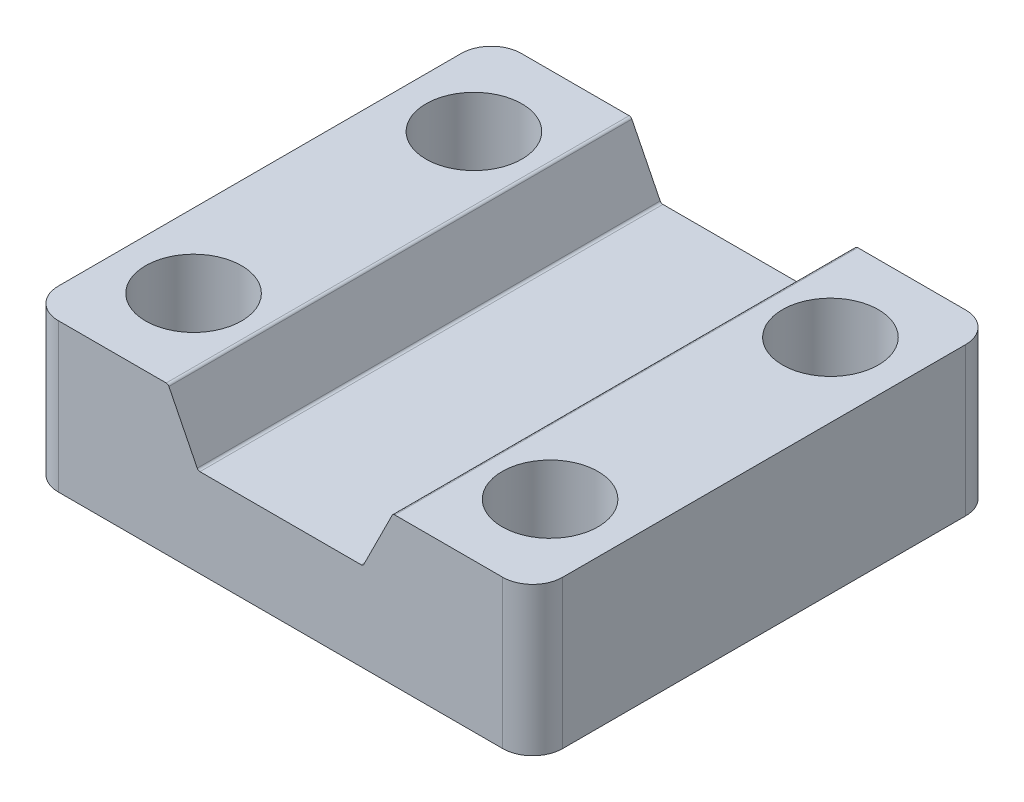
from build123d import *

# Parameters (mm, degrees)
ESQUISSE1_W             = 42.7228
ESQUISSE1_H             = 39.2176
BOSS_EXTRU_1_DEPTH      = 12.573
ESQUISSE2_W             = 13.97
ESQUISSE2_H             = 5.08
ENL_V_MAT_EXTRU_1_DEPTH = 40.2176
D_POUILLE1_ANGLE        = 26.565051177
PER_AGE1_D              = 8.128
PER_AGE1_DEPTH          = 12.573
CONG_1_R                = 0.254
CONG_2_R                = 2.54


with BuildPart() as part:
    # Esquisse1 → Boss.-Extru.1 (new body)
    with BuildSketch(Plane(origin=(0, 12.573, 0), x_dir=(1, 0, 0), z_dir=(0, 1, 0))):
        Rectangle(ESQUISSE1_W, ESQUISSE1_H)
    extrude(amount=-BOSS_EXTRU_1_DEPTH)

    # Esquisse2 → Enlèv. mat.-Extru.1 (cut, through all)
    with BuildSketch(Plane(origin=(0, 0, -19.6088), x_dir=(-1, 0, 0), z_dir=(0, 0, -1))):
        with Locations((0, 10.033)):
            Rectangle(ESQUISSE2_W, ESQUISSE2_H)
    extrude(amount=-ENL_V_MAT_EXTRU_1_DEPTH, mode=Mode.SUBTRACT)

    # Dépouille1
    d_pouille1_faces = [part.faces().sort_by_distance(p)[0] for p in [
        (-6.985, 10.033, 0),
        (6.985, 10.033, 0),
    ]]
    draft(d_pouille1_faces, Plane(origin=(6.985, 7.493, 19.6088), x_dir=(0, 0, 1), z_dir=(0, 1, 0)), D_POUILLE1_ANGLE)

    # Perçage1
    with Locations(Plane(origin=(0, 12.573, 0), x_dir=(1, 0, 0), z_dir=(0, 1, 0))):
        with Locations((15.1003, -11.8745), (-15.1003, 11.8745), (15.1003, 11.8745), (-15.1003, -11.8745)):
            Hole(PER_AGE1_D / 2, depth=PER_AGE1_DEPTH)

    # Congé1
    cong_1_edges = [part.edges().sort_by_distance(p)[0] for p in [
        (9.525, 12.573, 0),
        (-9.525, 12.573, 0),
        (-6.985, 7.493, 0),
        (6.985, 7.493, 0),
    ]]
    fillet(cong_1_edges, radius=CONG_1_R)

    # Congé2
    cong_2_edges = [part.edges().sort_by_distance(p)[0] for p in [
        (21.3614, 6.2865, -19.6088),
        (21.3614, 6.2865, 19.6088),
        (-21.3614, 6.2865, 19.6088),
        (-21.3614, 6.2865, -19.6088),
    ]]
    fillet(cong_2_edges, radius=CONG_2_R)


solid = part.part
